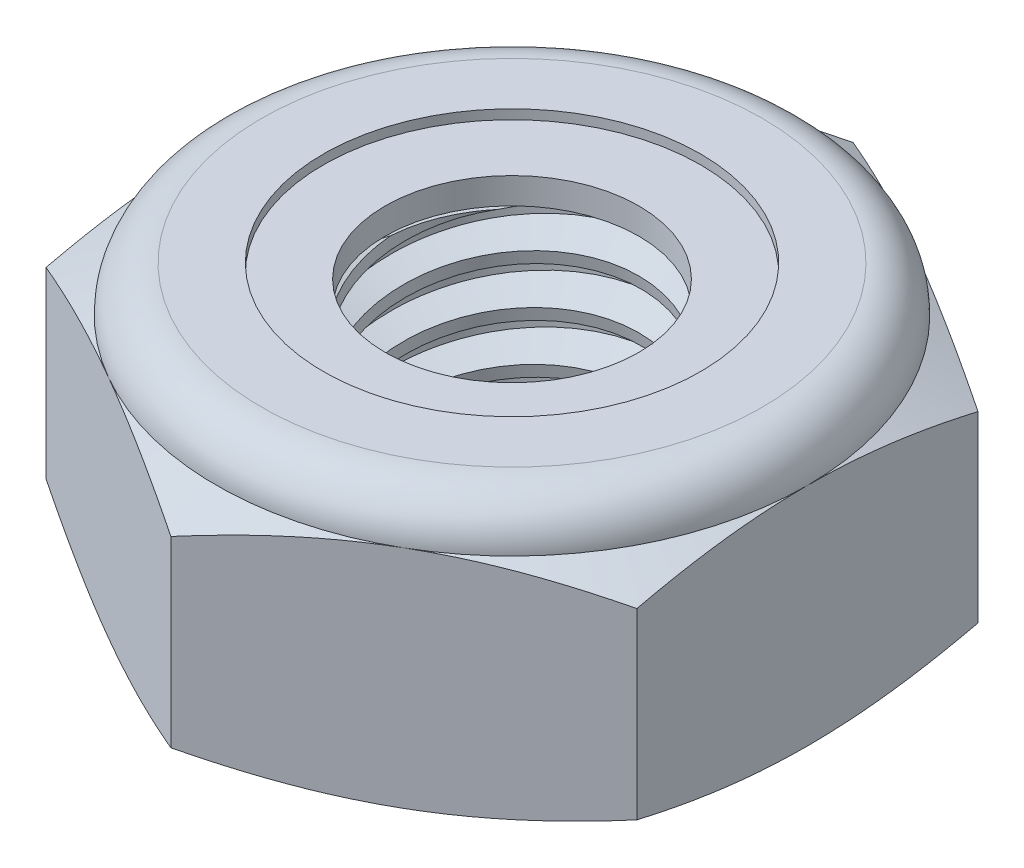
from build123d import *

# Parameters (mm, degrees)
EXTRUDE1_DEPTH      = 4.365625
SKETCH2_W           = 2.413
SKETCH2_H           = 4.365625
LPATTERN1_COUNT     = 6
LPATTERN1_PITCH     = 0.79375
LPATTERN1_COL_COUNT = 2
LPATTERN1_COL_PITCH = 0.79375


with BuildPart() as part:
    # Sketch1 → Extrude1 (new body)
    with BuildSketch(Plane(origin=(0, 0, 0), x_dir=(1, 0, 0), z_dir=(0, 1, 0))):
        Polygon((0, 5.499261314), (-4.7625, 2.749630657), (-4.7625, -2.749630657), (0, -5.499261314), (4.7625, -2.749630657), (4.7625, 2.749630657), align=None)
    extrude(amount=EXTRUDE1_DEPTH)

    # Sketch4 → Cut-Revolve2 (revolve, cut)
    with BuildSketch(Plane(origin=(0, 0, 0), x_dir=(0, 0, -1), z_dir=(1, 0, 0))):
        Polygon((0, 4.365625), (2.413, 4.365625), (2.045424837, 4.194221887), (2.045424837, 0.171403113), (2.413, 0), (0, 0), align=None)
    revolve(axis=Axis((0, 4.365625, 0), (0, 1, 0)), mode=Mode.SUBTRACT)


with BuildPart() as body_2:
    # Sketch2 → Revolve1 (revolve)
    with BuildSketch(Plane(origin=(0, 0, 0), x_dir=(0, 0, -1), z_dir=(1, 0, 0))):
        with Locations((1.2065, 2.1828125)):
            Rectangle(SKETCH2_W, SKETCH2_H)
    revolve(axis=Axis((0, -2.413, 0), (0, 1, 0)))

    # Sketch3 → Cut-Revolve1 (revolve, cut)
    with BuildSketch(Plane(origin=(0, 0, 0), x_dir=(0, 0, -1), z_dir=(1, 0, 0))):
        Polygon((2.429102527, 4.267721635), (2.541820218, 3.582398076), (2.077629892, 3.757430502), (2.045424837, 3.953237233), align=None)
    cut_revolve1 = revolve(axis=Axis((0, 4.365625, 0.139697061), (0, -0.986742581, -0.162293188)), mode=Mode.SUBTRACT)

    # LPattern1: Cut-Revolve1 ×6
    with Locations(*[(0, -i * LPATTERN1_PITCH, 0) for i in range(1, LPATTERN1_COUNT)]):
        add(cut_revolve1, mode=Mode.SUBTRACT)

    # LPattern1 col: Cut-Revolve1 ×2
    with Locations(*[(0, i * LPATTERN1_COL_PITCH, 0) for i in range(1, LPATTERN1_COL_COUNT)]):
        add(cut_revolve1, mode=Mode.SUBTRACT)


with BuildPart() as part_1:
    add(part.part)

    # Combine1: cut body 2
    add(body_2.part, mode=Mode.SUBTRACT)

    # Sketch5 → Cut-Revolve3 (revolve, cut)
    with BuildSketch(Plane(origin=(0, 0, 0), x_dir=(0, 0, -1), z_dir=(1, 0, 0))):
        with BuildLine():
            Line((0, 0), (4.7625, 0))
            Line((4.7625, 0), (5.499261314, 0.343557443))
            Line((5.499261314, 0.343557443), (5.499261314, 3.29446339))
            Line((5.499261314, 3.29446339), (4.7625, 3.638020833))
            ThreePointArc((4.7625, 3.638020833), (4.549389674, 4.152514674), (4.034895833, 4.365625))
            Line((4.034895833, 4.365625), (4.034895833, 5.635625))
            Line((4.034895833, 5.635625), (6.769261314, 5.635625))
            Line((6.769261314, 5.635625), (6.769261314, -1.27))
            Line((6.769261314, -1.27), (0, -1.27))
            Line((0, -1.27), (0, 0))
        make_face()
    revolve(axis=Axis((0, 0, 0), (0, 1, 0)), mode=Mode.SUBTRACT)

    # Sketch6 → Cut-Revolve4 (revolve, cut)
    with BuildSketch(Plane(origin=(0, 0, 0), x_dir=(0, 0, -1), z_dir=(1, 0, 0))):
        with BuildLine():
            Line((0, 3.638020833), (4.6101, 3.638020833))
            ThreePointArc((4.6101, 3.638020833), (4.4416266, 4.0447516), (4.034895833, 4.213225))
            Line((4.034895833, 4.213225), (3.040160335, 4.213225))
            Line((3.040160335, 4.213225), (3.040160335, 5.635625))
            Line((3.040160335, 5.635625), (0, 5.635625))
            Line((0, 5.635625), (0, 3.638020833))
        make_face()
    revolve(axis=Axis((0, 5.635625, 0), (0, 1, 0)), mode=Mode.SUBTRACT)


with BuildPart() as body_2_2:
    # Sketch7 → Revolve2 (revolve)
    with BuildSketch(Plane(origin=(0, 0, 0), x_dir=(0, 0, -1), z_dir=(1, 0, 0))):
        with BuildLine():
            Line((2.045424837, 3.714220833), (4.528047654, 3.714220833))
            ThreePointArc((4.528047654, 3.714220833), (4.359688876, 4.016854092), (4.034895833, 4.137025))
            Line((4.034895833, 4.137025), (2.045424837, 4.137025))
            Line((2.045424837, 4.137025), (2.045424837, 3.714220833))
        make_face()
    revolve(axis=Axis((0, 3.714220833, 0), (0, 1, 0)))


solid = Compound([part_1.part, body_2_2.part])
